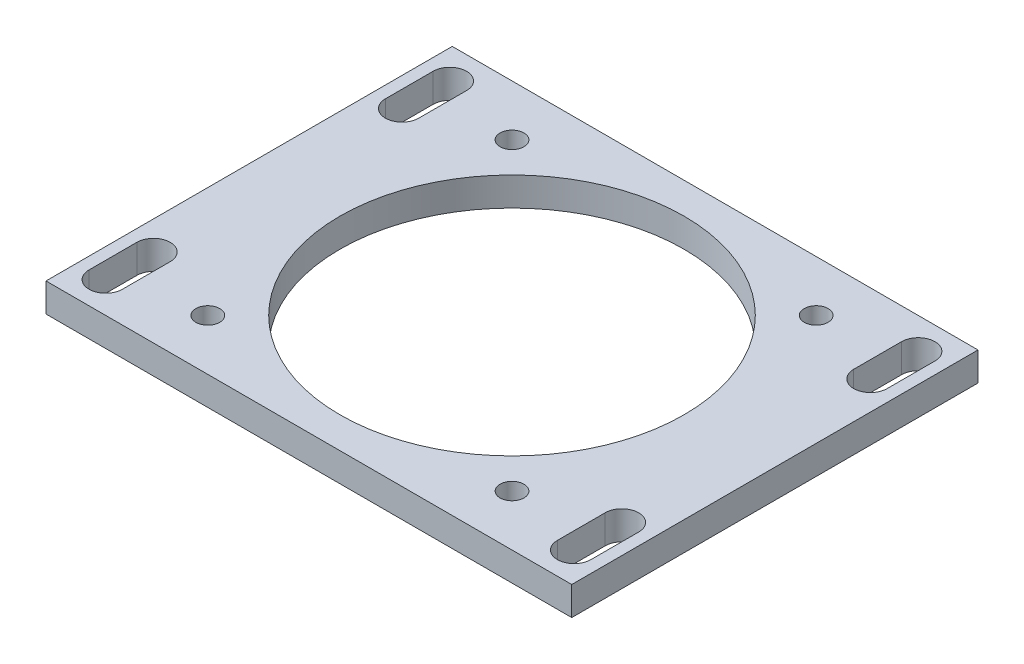
from build123d import *

# Parameters (mm, degrees)
SKETCH_1_W             = 110
SKETCH_1_H             = 85
EXTRUDE_1_DEPTH        = 6
SKETCH_2_R             = 36
CUT_EXTRUDE_1_DEPTH    = 10
CUT_EXTRUDE_2_DEPTH    = 10
HOLE_WIZARD_M6_1_D     = 5
HOLE_WIZARD_M6_1_DEPTH = 15
HOLE_WIZARD_M6_1_TIP   = 1.502151548


with BuildPart() as part:
    # 草图1 → 凸台-拉伸1 (new body)
    with BuildSketch(Plane(origin=(0, 0, 0), x_dir=(1, 0, 0), z_dir=(0, 1, 0))):
        Rectangle(SKETCH_1_W, SKETCH_1_H)
    extrude(amount=EXTRUDE_1_DEPTH)

    # 草图2 → 切除-拉伸1 (cut)
    with BuildSketch(Plane(origin=(0, 6, 0), x_dir=(1, 0, 0), z_dir=(0, 1, 0))):
        Circle(SKETCH_2_R)
    extrude(amount=-CUT_EXTRUDE_1_DEPTH, mode=Mode.SUBTRACT)

    # 草图3 → 切除-拉伸2 (cut)
    with BuildSketch(Plane(origin=(0, 6, 0), x_dir=(1, 0, 0), z_dir=(0, 1, 0))):
        with BuildLine():
            Line((-45.5, 36), (-45.5, 26))
            ThreePointArc((-45.5, 26), (-49, 22.5), (-52.5, 26))
            Line((-52.5, 26), (-52.5, 36))
            ThreePointArc((-52.5, 36), (-49, 39.5), (-45.5, 36))
        make_face()
        with BuildLine():
            Line((45.5, 36), (45.5, 26))
            ThreePointArc((45.5, 26), (49, 22.5), (52.5, 26))
            Line((52.5, 26), (52.5, 36))
            ThreePointArc((52.5, 36), (49, 39.5), (45.5, 36))
        make_face()
        with BuildLine():
            Line((-45.5, -36), (-45.5, -26))
            ThreePointArc((-45.5, -26), (-49, -22.5), (-52.5, -26))
            Line((-52.5, -26), (-52.5, -36))
            ThreePointArc((-52.5, -36), (-49, -39.5), (-45.5, -36))
        make_face()
        with BuildLine():
            Line((45.5, -36), (45.5, -26))
            ThreePointArc((45.5, -26), (49, -22.5), (52.5, -26))
            Line((52.5, -26), (52.5, -36))
            ThreePointArc((52.5, -36), (49, -39.5), (45.5, -36))
        make_face()
    extrude(amount=-CUT_EXTRUDE_2_DEPTH, mode=Mode.SUBTRACT)

    # M6 螺纹孔1
    with Locations(Plane(origin=(-31.819805153, 6, -31.819805153), x_dir=(0, 0, 1), z_dir=(0, 1, 0))):
        with Locations((0, 0), (0, 63.639610306), (63.639610306, 63.639610306), (63.639610306, 0)):
            Hole(HOLE_WIZARD_M6_1_D / 2, depth=HOLE_WIZARD_M6_1_DEPTH)
            with Locations((0, 0, -(HOLE_WIZARD_M6_1_DEPTH + HOLE_WIZARD_M6_1_TIP / 2))):  # 118° drill point
                Cone(0, HOLE_WIZARD_M6_1_D / 2, HOLE_WIZARD_M6_1_TIP, mode=Mode.SUBTRACT)


solid = part.part
